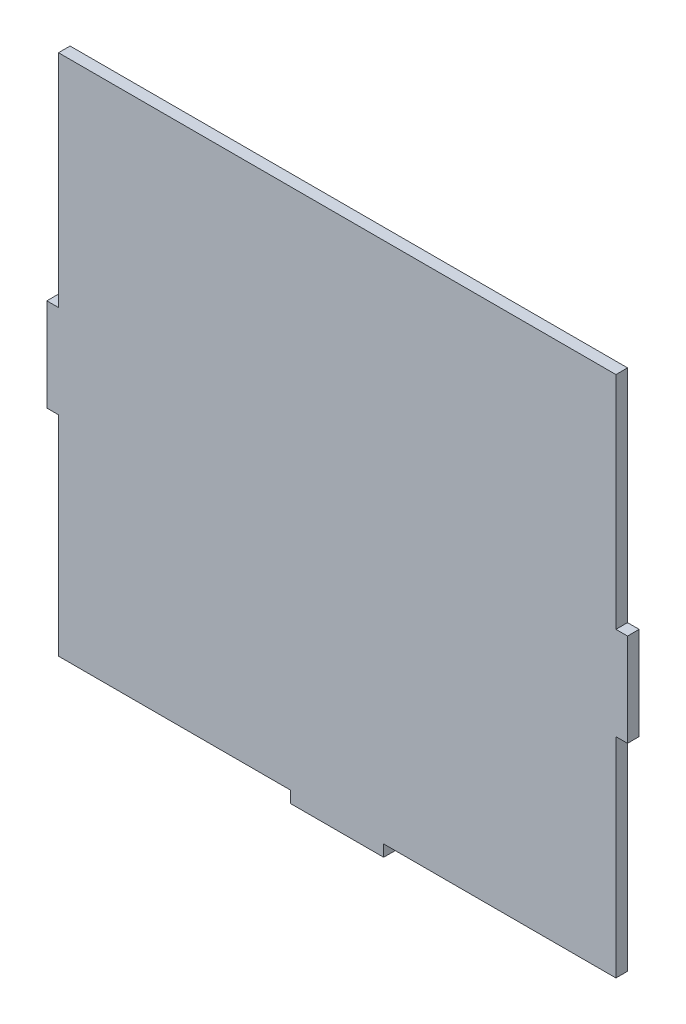
from build123d import *

# Parameters (mm, degrees)
BOSS_EXTRU_1_DEPTH = 5


with BuildPart() as part:
    # Esquisse1 → Boss.-Extru.1 (new body)
    with BuildSketch(Plane.XY):
        Polygon((5, -91.519772216), (245, -91.519772216), (245, -186.519772216), (250, -186.519772216), (250, -226.519772216), (245, -226.519772216), (245, -316.519772216), (145, -316.519772216), (145, -321.519772216), (105, -321.519772216), (105, -316.519772216), (5, -316.519772216), (5, -226.519772216), (0, -226.519772216), (0, -186.519772216), (5, -186.519772216), align=None)
    extrude(amount=BOSS_EXTRU_1_DEPTH)


solid = part.part
